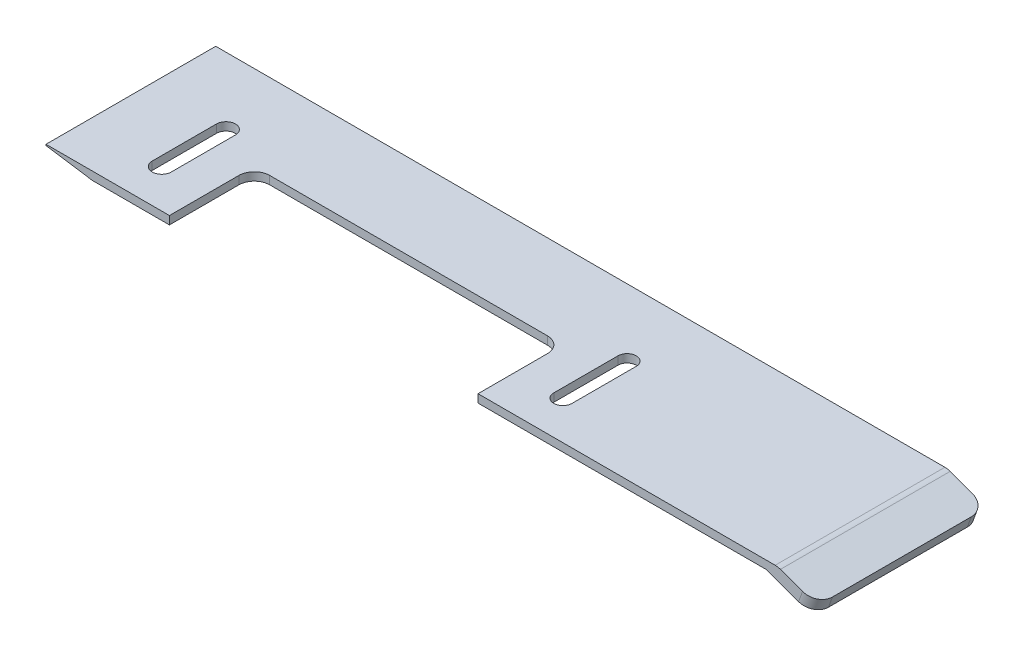
from build123d import *

# Parameters (mm, degrees)
BOSS_EXTRUDE1_DEPTH = 22
FILLET10_R          = 2
FILLET11_R          = 2
SKETCH4_W           = 40
SKETCH4_H           = 18.455921649
CUT_EXTRUDE1_DEPTH  = 30
FILLET12_R          = 2


with BuildPart() as part:
    # Sketch2 → Boss-Extrude1 (new body)
    with BuildSketch(Plane.XY):
        Polygon((-70.922010647, 6.21881141), (23.946585559, 6.21881141), (29.020925711, 4.371902636), (28.507895496, 2.962363705), (22.467605346, 5.160849526), (-64.922010647, 5.160849526), (-70.922010647, 6.060990271), align=None)
    extrude(amount=BOSS_EXTRUDE1_DEPTH)

    # Fillet10
    fillet10_edges = [part.edges().sort_by_distance(p)[0] for p in [
        (28.764410604, 3.667133171, 22),
        (28.764410604, 3.667133171, 0),
    ]]
    fillet(fillet10_edges, radius=FILLET10_R)

    # Fillet11
    fillet11_edges = [part.edges().sort_by_distance(p)[0] for p in [
        (23.946585559, 6.21881141, 11),
    ]]
    fillet(fillet11_edges, radius=FILLET11_R)

    # Sketch4 → Cut-Extrude1 (cut)
    with BuildSketch(Plane.XZ.offset(-5.160849526)):
        with Locations((-34.922010647, 20.227960825)):
            Rectangle(SKETCH4_W, SKETCH4_H)
        with BuildLine():
            Line((-59.68856271, 8.67422642), (-59.68856271, 17))
            ThreePointArc((-59.68856271, 17), (-60.922010647, 18.233447938), (-62.155458585, 17))
            Line((-62.155458585, 17), (-62.155458585, 8.67422642))
            ThreePointArc((-62.155458585, 8.67422642), (-60.922010647, 7.440778483), (-59.68856271, 8.67422642))
        make_face()
        with BuildLine():
            Line((-7.739956374, 8.67422642), (-7.739956374, 17))
            ThreePointArc((-7.739956374, 17), (-8.922010647, 18.182054274), (-10.104064921, 17))
            Line((-10.104064921, 17), (-10.104064921, 8.67422642))
            ThreePointArc((-10.104064921, 8.67422642), (-8.922010647, 7.492172147), (-7.739956374, 8.67422642))
        make_face()
    extrude(amount=-CUT_EXTRUDE1_DEPTH, mode=Mode.SUBTRACT)

    # Fillet12
    fillet12_edges = [part.edges().sort_by_distance(p)[0] for p in [
        (-14.922010647, 5.689830468, 11),
        (-54.922010647, 5.689830468, 11),
    ]]
    fillet(fillet12_edges, radius=FILLET12_R)


solid = part.part
